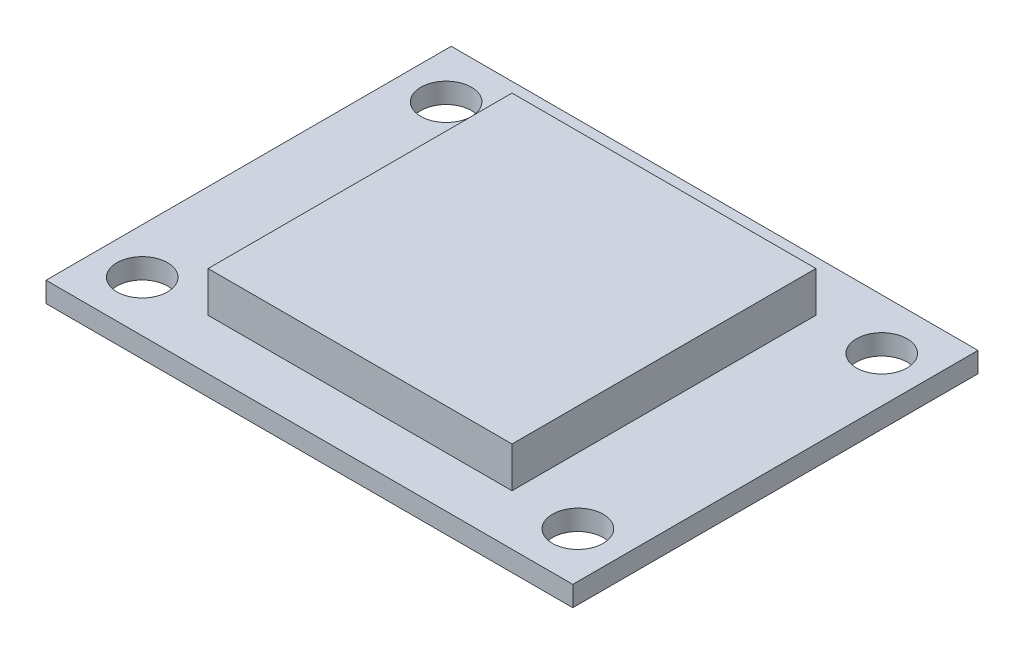
from build123d import *

# Parameters (mm, degrees)
SKETCH1_W           = 26
SKETCH1_H           = 20
BOSS_EXTRUDE1_DEPTH = 1
SKETCH2_R           = 1.25
CUT_EXTRUDE1_DEPTH  = 1
SKETCH3_W           = 15
SKETCH3_H           = 15
BOSS_EXTRUDE2_DEPTH = 3


with BuildPart() as part:
    # Sketch1 → Boss-Extrude1 (new body)
    with BuildSketch(Plane(origin=(0, 0, 0), x_dir=(1, 0, 0), z_dir=(0, 1, 0))):
        Rectangle(SKETCH1_W, SKETCH1_H)
    extrude(amount=BOSS_EXTRUDE1_DEPTH)

    # Sketch2 → Cut-Extrude1 (cut)
    with BuildSketch(Plane(origin=(0, 0, 0), x_dir=(1, 0, 0), z_dir=(0, 1, 0))):
        with Locations((-10.75, 7.5)):
            Circle(SKETCH2_R)
        with Locations((-10.75, -7.5)):
            Circle(SKETCH2_R)
        with Locations((10.75, -7.5)):
            Circle(SKETCH2_R)
        with Locations((10.75, 7.5)):
            Circle(SKETCH2_R)
    extrude(amount=CUT_EXTRUDE1_DEPTH, mode=Mode.SUBTRACT)

    # Sketch3 → Boss-Extrude2 (add)
    with BuildSketch(Plane(origin=(0, 0, 0), x_dir=(1, 0, 0), z_dir=(0, 1, 0))):
        Rectangle(SKETCH3_W, SKETCH3_H)
    extrude(amount=BOSS_EXTRUDE2_DEPTH)


solid = part.part
